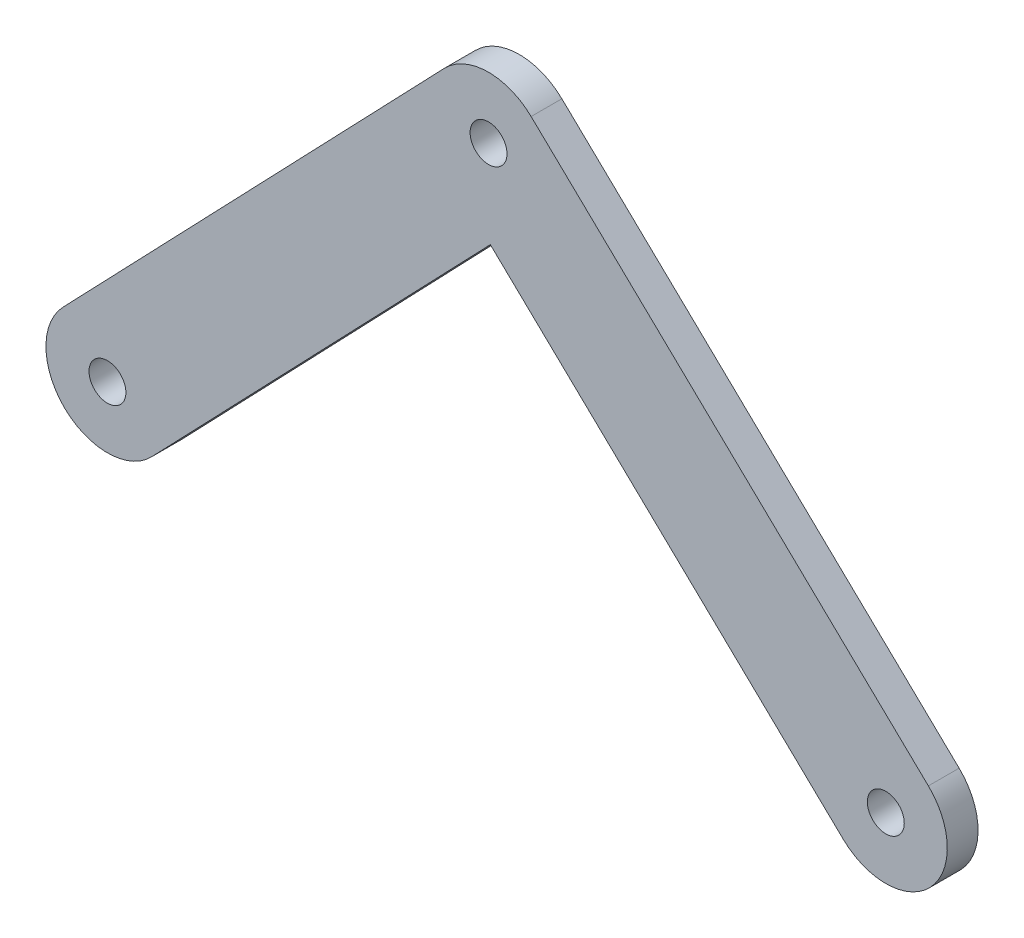
from build123d import *

# Parameters (mm, degrees)
SKETCH1_R           = 3
BOSS_EXTRUDE2_DEPTH = 5


with BuildPart() as part:
    # Sketch1 → Boss-Extrude2 (new body)
    with BuildSketch(Plane.XY):
        with BuildLine():
            Line((0.29412641, -14.13907669), (-54.75624353, -71.528460831))
            ThreePointArc((-54.75624353, -71.528460831), (-68.895320221, -71.822587241), (-69.18944663, -57.68351055))
            Line((-69.18944663, -57.68351055), (-7.21660155, 6.92247514))
            ThreePointArc((-7.21660155, 6.92247514), (-0.207978779, 9.997837007), (6.92247514, 7.21660155))
            Line((6.92247514, 7.21660155), (71.525492216, -54.753395907))
            ThreePointArc((71.525492216, -54.753395907), (71.819618625, -68.892472597), (57.680541935, -69.186599007))
            Line((57.680541935, -69.186599007), (0.29412641, -14.13907669))
        make_face()
        with Locations((-61.97284508, -64.605985691)):
            Circle(SKETCH1_R, mode=Mode.SUBTRACT)
        with Locations((64.603017075, -61.969997457)):
            Circle(SKETCH1_R, mode=Mode.SUBTRACT)
        Circle(SKETCH1_R, mode=Mode.SUBTRACT)
    extrude(amount=BOSS_EXTRUDE2_DEPTH)


solid = part.part
